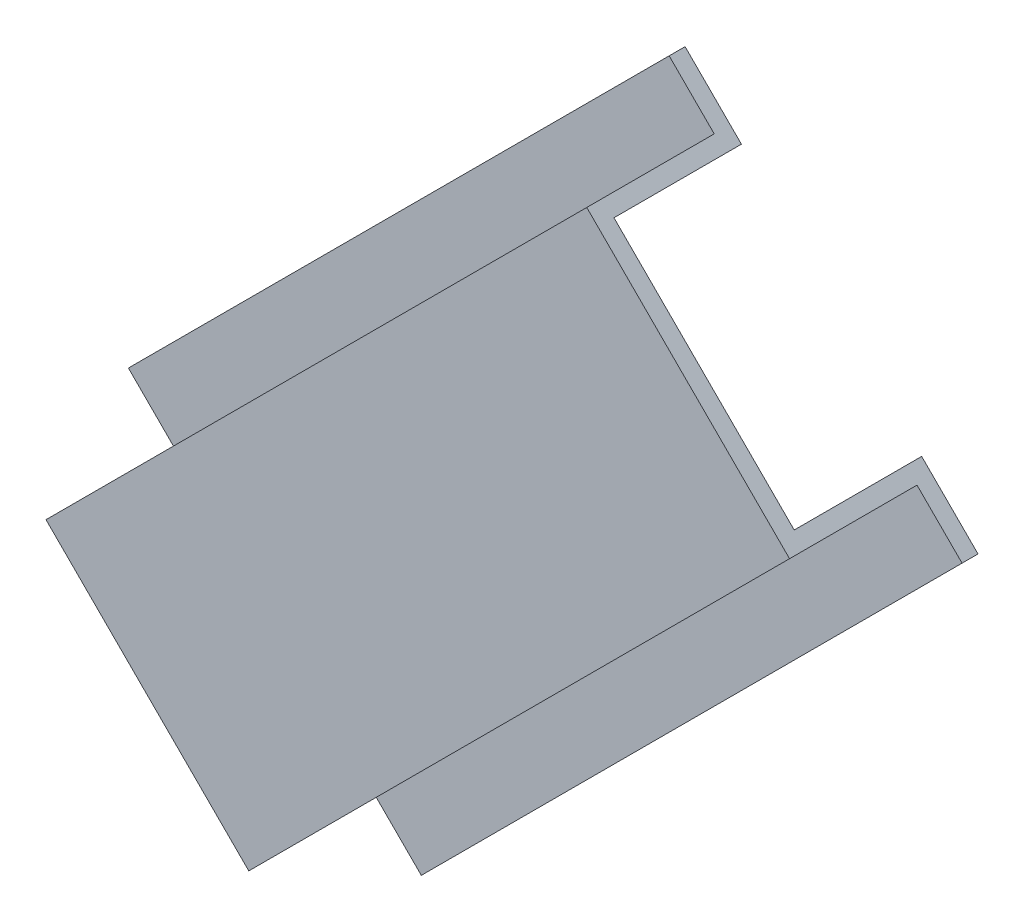
from build123d import *

# Parameters (mm, degrees)
BOSS_EXTRUDE1_DEPTH = 152.4


with BuildPart() as part:
    # Sketch2 → Boss-Extrude1 (new body)
    with BuildSketch(Plane(origin=(-53.881536726, -53.881536726, 0), x_dir=(0, 0, 1), z_dir=(-0.707106781, -0.707106781, 0))):
        Polygon((3.175, -28.575), (28.575, -28.575), (28.575, 28.575), (3.175, 28.575), (3.175, 41.275), (0, 41.275), (0, 25.4), (25.4, 25.4), (25.4, -25.4), (0, -25.4), (0, -41.275), (3.175, -41.275), align=None)
    extrude(amount=-BOSS_EXTRUDE1_DEPTH)


solid = part.part
